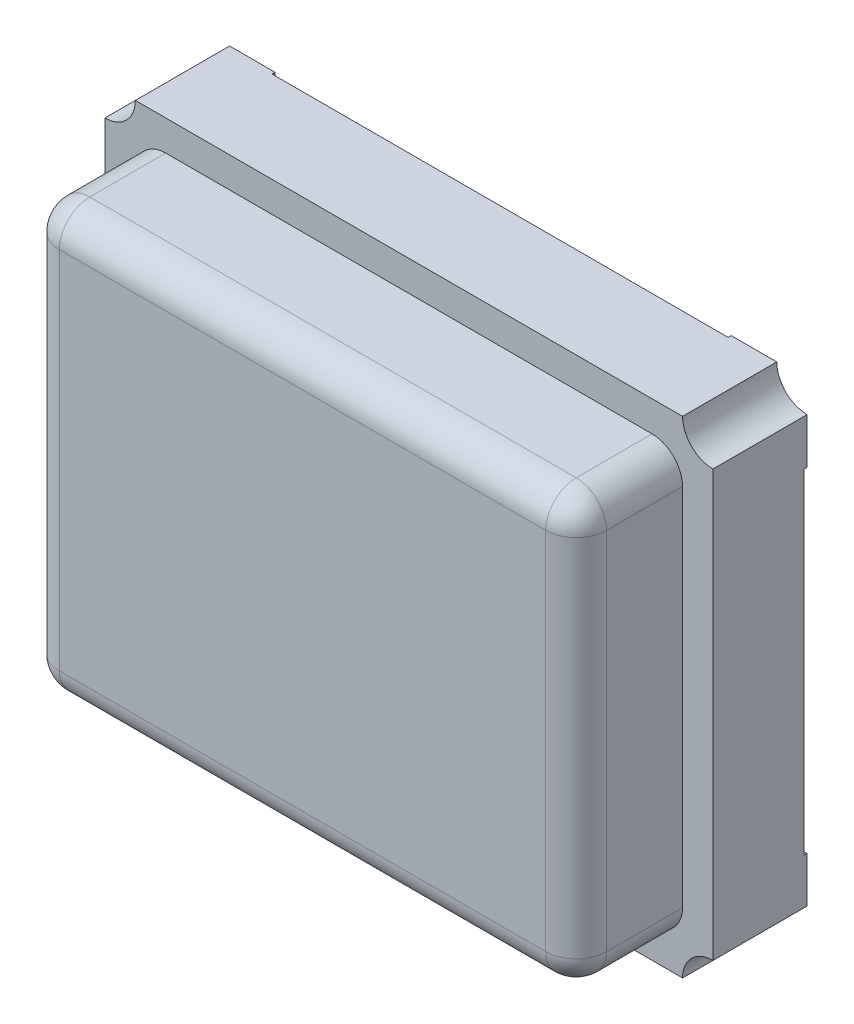
from build123d import *

# Parameters (mm, degrees)
SKETCH1_W           = 2
SKETCH1_H           = 1.6
BOSS_EXTRUDE1_DEPTH = 0.3
SKETCH2_W           = 1.8
SKETCH2_H           = 1.4
BOSS_EXTRUDE2_DEPTH = 0.35
FILLET1_R           = 0.1
CUT_EXTRUDE1_DEPTH  = 1.3
SKETCH4_W           = 0.5
SKETCH4_H           = 0.5
BOSS_EXTRUDE3_DEPTH = 0.01
FILLET2_R           = 0.1


with BuildPart() as part:
    # Sketch1 → Boss-Extrude1 (new body)
    with BuildSketch(Plane.XY):
        with Locations((1, 0.8)):
            Rectangle(SKETCH1_W, SKETCH1_H)
    extrude(amount=BOSS_EXTRUDE1_DEPTH)

    # Sketch2 → Boss-Extrude2 (add)
    with BuildSketch(Plane.XY.offset(0.3)):
        with Locations((1, 0.8)):
            Rectangle(SKETCH2_W, SKETCH2_H)
    extrude(amount=BOSS_EXTRUDE2_DEPTH)

    # Fillet1
    fillet1_edges = [part.edges().sort_by_distance(p)[0] for p in [
        (0.1, 1.5, 0.475),
        (0.1, 0.1, 0.475),
        (1.9, 0.1, 0.475),
        (1.9, 1.5, 0.475),
    ]]
    fillet(fillet1_edges, radius=FILLET1_R)

    # Sketch3 → Cut-Extrude1 (cut, through all)
    with BuildSketch(Plane.XY.offset(0.3)):
        with BuildLine():
            Line((0, 1.6), (0.1, 1.6))
            ThreePointArc((0.1, 1.6), (0.070710678, 1.529289322), (0, 1.5))
            Line((0, 1.5), (0, 1.6))
        make_face()
        with BuildLine():
            Line((0, 0), (0, 0.1))
            ThreePointArc((0, 0.1), (0.070710678, 0.070710678), (0.1, 0))
            Line((0.1, 0), (0, 0))
        make_face()
        with BuildLine():
            Line((2, 1.6), (1.9, 1.6))
            ThreePointArc((1.9, 1.6), (1.929289322, 1.529289322), (2, 1.5))
            Line((2, 1.5), (2, 1.6))
        make_face()
        with BuildLine():
            Line((2, 0), (2, 0.1))
            ThreePointArc((2, 0.1), (1.929289322, 0.070710678), (1.9, 0))
            Line((1.9, 0), (2, 0))
        make_face()
    extrude(amount=-CUT_EXTRUDE1_DEPTH, mode=Mode.SUBTRACT)

    # Sketch4 → Boss-Extrude3 (add)
    with BuildSketch(Plane(origin=(0, 0, 0), x_dir=(-1, 0, 0), z_dir=(0, 0, -1))):
        with BuildLine():
            Line((-2, 1.5), (-2, 1.35))
            Line((-2, 1.35), (-1.899114856, 1.35))
            Line((-1.899114856, 1.35), (-1.899114856, 1.500209267))
            Line((-1.899114856, 1.500209267), (-1.75, 1.500209267))
            Line((-1.75, 1.500209267), (-1.75, 1.6))
            Line((-1.75, 1.6), (-1.9, 1.6))
            ThreePointArc((-1.9, 1.6), (-1.929289322, 1.529289322), (-2, 1.5))
        make_face()
        with Locations((-1.649114856, 1.250209267)):
            Rectangle(SKETCH4_W, SKETCH4_H)
        with Locations((-1.649114856, 0.350209267)):
            Rectangle(SKETCH4_W, SKETCH4_H)
        with BuildLine():
            Line((-1.899114856, 0.25), (-2, 0.25))
            Line((-2, 0.25), (-2, 0.1))
            ThreePointArc((-2, 0.1), (-1.929289322, 0.070710678), (-1.9, 0))
            Line((-1.9, 0), (-1.75, 0))
            Line((-1.75, 0), (-1.75, 0.100209267))
            Line((-1.75, 0.100209267), (-1.899114856, 0.100209267))
            Line((-1.899114856, 0.100209267), (-1.899114856, 0.25))
        make_face()
        Polygon((-1.452147865, 0.653242275), (-1.558151985, 0.600209267), (-1.399114856, 0.600209267), (-1.399114856, 0.520644271), (-1.346081848, 0.547176258), (-0.546966991, 0.946966991), (-0.440962871, 1), (-0.6, 1), (-0.6, 1.079564996), (-0.653033009, 1.053033009), align=None)
        with Locations((-0.35, 0.35)):
            Rectangle(SKETCH4_W, SKETCH4_H)
        with Locations((-0.35, 1.25)):
            Rectangle(SKETCH4_W, SKETCH4_H)
        with BuildLine():
            Line((-0.1, 1.6), (-0.25, 1.6))
            Line((-0.25, 1.6), (-0.25, 1.5))
            Line((-0.25, 1.5), (-0.1, 1.5))
            Line((-0.1, 1.5), (-0.1, 1.35))
            Line((-0.1, 1.35), (0, 1.35))
            Line((0, 1.35), (0, 1.5))
            ThreePointArc((0, 1.5), (-0.070710678, 1.529289322), (-0.1, 1.6))
        make_face()
        with BuildLine():
            Line((-0.25, 0.1), (-0.25, 0))
            Line((-0.25, 0), (-0.1, 0))
            ThreePointArc((-0.1, 0), (-0.070710678, 0.070710678), (0, 0.1))
            Line((0, 0.1), (0, 0.25))
            Line((0, 0.25), (-0.1, 0.25))
            Line((-0.1, 0.25), (-0.1, 0.1))
            Line((-0.1, 0.1), (-0.25, 0.1))
        make_face()
    extrude(amount=BOSS_EXTRUDE3_DEPTH)

    # Fillet2
    fillet2_edges = [part.edges().sort_by_distance(p)[0] for p in [
        (1, 1.5, 0.65),
        (1.9, 0.8, 0.65),
        (0.1, 0.8, 0.65),
        (1, 0.1, 0.65),
        (1.870710678, 0.129289322, 0.65),
        (0.129289322, 0.129289322, 0.65),
        (0.129289322, 1.470710678, 0.65),
        (1.870710678, 1.470710678, 0.65),
    ]]
    fillet(fillet2_edges, radius=FILLET2_R)


solid = part.part
